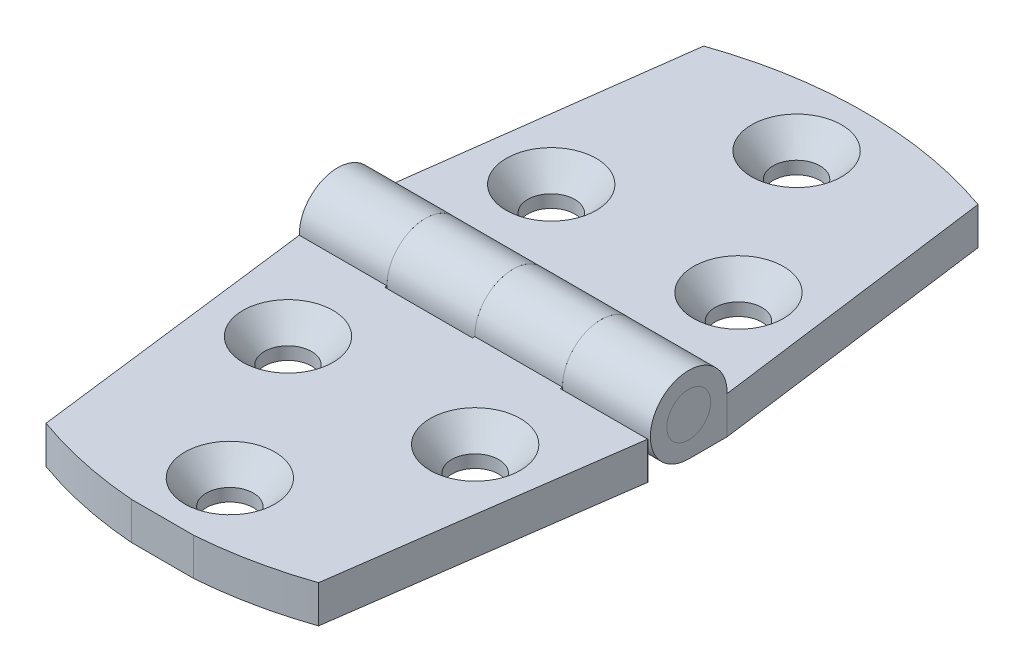
from build123d import *

# Parameters (mm, degrees)
SKETCH1_R                                    = 2.38125
LEFT_LEAF_DEPTH                              = 19.05
SKETCH2_W                                    = 9.525
SKETCH2_H                                    = 8.588375
CUT_EXTRUDE1_DEPTH                           = 5.1671875
CUT_EXTRUDE1_DEPTH_BACK                      = 5.1671875
SKETCH3_R                                    = 2.38125
RIGHT_LEAF_DEPTH                             = 19.05
SKETCH9_W                                    = 9.525
SKETCH9_H                                    = 8.842375
CUT_EXTRUDE2_DEPTH                           = 5.1671875
CUT_EXTRUDE2_DEPTH_BACK                      = 5.1671875
SKETCH10_R                                   = 2.38125
EXTRUDE1_DEPTH                               = 19.05
CUT_EXTRUDE3_DEPTH                           = 5.064
CSK_FOR_10_FLAT_HEAD_MACHINE_SCREW1_AT_COUNT = 2
CSK_FOR_10_FLAT_HEAD_MACHINE_SCREW1_AT_PITCH = 19.351919642
CSK_FOR_10_FLAT_HEAD_MACHINE_SCREW1_2_COUNT  = 2
CSK_FOR_10_FLAT_HEAD_MACHINE_SCREW1_2_PITCH  = 19.351919642
CSK_FOR_10_FLAT_HEAD_MACHINE_SCREW1_3_COUNT  = 2
CSK_FOR_10_FLAT_HEAD_MACHINE_SCREW1_3_PITCH  = 46.176896585
CSK_FOR_10_FLAT_HEAD_MACHINE_SCREW1_4_COUNT  = 2
CSK_FOR_10_FLAT_HEAD_MACHINE_SCREW1_4_PITCH  = 46.176896585
CSK_FOR_10_FLAT_HEAD_MACHINE_SCREW1_5_COUNT  = 2
CSK_FOR_10_FLAT_HEAD_MACHINE_SCREW1_5_PITCH  = 61.515625


with BuildPart() as part:
    # Sketch1 → Left Leaf (new body, symmetric)
    with BuildSketch(Plane(origin=(0, 0, 0), x_dir=(0, 0, -1), z_dir=(1, 0, 0))):
        with BuildLine():
            Line((-38.1, -0.1031875), (-4.165909745, -0.1031875))
            ThreePointArc((-4.165909745, -0.1031875), (2.909935566, 2.982905741), (0, -4.1671875))
            Line((0, -4.1671875), (-38.1, -4.1671875))
            Line((-38.1, -4.1671875), (-38.1, -0.1031875))
        make_face()
        Circle(SKETCH1_R, mode=Mode.SUBTRACT)
    extrude(amount=LEFT_LEAF_DEPTH, both=True)

    # Sketch2 → Cut-Extrude1 (cut, two sides)
    with BuildSketch(Plane(origin=(0, 0, 0), x_dir=(1, 0, 0), z_dir=(0, 1, 0))) as cut_extrude1_sk:
        with Locations((-4.7625, -0.127)):
            Rectangle(SKETCH2_W, SKETCH2_H)
        with Locations((14.2875, -0.127)):
            Rectangle(SKETCH2_W, SKETCH2_H)
    extrude(amount=CUT_EXTRUDE1_DEPTH, mode=Mode.SUBTRACT)
    extrude(cut_extrude1_sk.sketch, amount=-CUT_EXTRUDE1_DEPTH_BACK, mode=Mode.SUBTRACT)


with BuildPart() as body_2:
    # Sketch3 → Right Leaf (new body, symmetric)
    with BuildSketch(Plane(origin=(0, 0, 0), x_dir=(0, 0, -1), z_dir=(1, 0, 0))):
        with BuildLine():
            Line((38.1, -0.1031875), (38.1, -4.1671875))
            Line((38.1, -4.1671875), (0, -4.1671875))
            ThreePointArc((0, -4.1671875), (-2.909935566, 2.982905741), (4.165909745, -0.1031875))
            Line((4.165909745, -0.1031875), (38.1, -0.1031875))
        make_face()
        Circle(SKETCH3_R, mode=Mode.SUBTRACT)
    extrude(amount=RIGHT_LEAF_DEPTH, both=True)

    # Sketch9 → Cut-Extrude2 (cut, two sides)
    with BuildSketch(Plane(origin=(0, 0, 0), x_dir=(1, 0, 0), z_dir=(0, 1, 0))) as cut_extrude2_sk:
        with Locations((-14.2875, 0)):
            Rectangle(SKETCH9_W, SKETCH9_H)
        with Locations((4.7625, 0)):
            Rectangle(SKETCH9_W, SKETCH9_H)
    extrude(amount=CUT_EXTRUDE2_DEPTH, mode=Mode.SUBTRACT)
    extrude(cut_extrude2_sk.sketch, amount=-CUT_EXTRUDE2_DEPTH_BACK, mode=Mode.SUBTRACT)


with BuildPart() as body_3:
    # Sketch10 → Extrude1 (new body, symmetric)
    with BuildSketch(Plane(origin=(0, 0, 0), x_dir=(0, 0, -1), z_dir=(1, 0, 0))):
        Circle(SKETCH10_R)
    extrude(amount=EXTRUDE1_DEPTH, both=True)


with BuildPart() as cut_extrude3_tool:
    # Sketch13 → Cut-Extrude3 (new body, through all)
    with BuildSketch(Plane(origin=(0, -0.1031875, 0), x_dir=(-1, 0, 0), z_dir=(0, 1, 0))):
        with BuildLine():
            Line((19.022219059, -4.167094897), (14.889264695, -35.56))
            ThreePointArc((14.889264695, -35.56), (0, -38.1), (-14.889264695, -35.56))
            Line((-14.889264695, -35.56), (-19.05, -4.170764834))
            Line((-19.05, -4.170764834), (-24.251524546, -4.170764834))
            Line((-24.251524546, -4.170764834), (-24.251524546, -58.581674997))
            Line((-24.251524546, -58.581674997), (25.352500978, -58.581674997))
            Line((25.352500978, -58.581674997), (25.352500978, -4.167094897))
            Line((25.352500978, -4.167094897), (19.022219059, -4.167094897))
        make_face()
        with BuildLine():
            Line((-23.86002214, 58.869046819), (-24.22275751, 4.459345774))
            Line((-24.22275751, 4.459345774), (-19.021348553, 4.424669329))
            Line((-19.021348553, 4.424669329), (-14.651446465, 35.785469037))
            ThreePointArc((-14.651446465, 35.785469037), (0.254420506, 38.226151932), (15.126421188, 35.586947714))
            Line((15.126421188, 35.586947714), (19.05, 4.1671875))
            Line((19.05, 4.1671875), (25.380141248, 4.124986089))
            Line((25.380141248, 4.124986089), (25.742901085, 58.53835699))
            Line((25.742901085, 58.53835699), (-23.86002214, 58.869046819))
        make_face()
    extrude(amount=-CUT_EXTRUDE3_DEPTH)


with BuildPart() as part_1:
    add(part.part)

    # Cut-Extrude3: cut by cut_extrude3_tool
    add(cut_extrude3_tool.part, mode=Mode.SUBTRACT)


with BuildPart() as body_2_1:
    add(body_2.part)

    # Cut-Extrude3: cut by cut_extrude3_tool
    add(cut_extrude3_tool.part, mode=Mode.SUBTRACT)

    # Sketch12 → CSK for #10 Flat Head Machine Screw1 (revolve, cut)
    with BuildSketch(Plane(origin=(0, -0.1031875, -30.7578125), x_dir=(0, 0, 1), z_dir=(1, 0, 0))):
        Polygon((0, 0), (0, 4.064), (2.5527, 4.064), (2.5527, 2.688180894), (4.8895, 0), align=None)
    csk_for_10_flat_head_machine_screw1 = revolve(axis=Axis((0, 6.2468125, -30.7578125), (0, -1, 0)), mode=Mode.SUBTRACT)

    # CSK for #10 Flat Head Machine Screw1 at: CSK for #10 Flat Head Machine Screw1 ×2
    with Locations(*[Vector(-0.525012515, 0, 0.851094507) * (i * CSK_FOR_10_FLAT_HEAD_MACHINE_SCREW1_AT_PITCH) for i in range(1, CSK_FOR_10_FLAT_HEAD_MACHINE_SCREW1_AT_COUNT)]):
        add(csk_for_10_flat_head_machine_screw1, mode=Mode.SUBTRACT)

    # CSK for _10 Flat Head Machine Screw1 2: CSK for #10 Flat Head Machine Screw1 ×2
    with Locations(*[Vector(0.525012515, 0, 0.851094507) * (i * CSK_FOR_10_FLAT_HEAD_MACHINE_SCREW1_2_PITCH) for i in range(1, CSK_FOR_10_FLAT_HEAD_MACHINE_SCREW1_2_COUNT)]):
        add(csk_for_10_flat_head_machine_screw1, mode=Mode.SUBTRACT)


with BuildPart() as part_2:
    add(part_1.part)

    # CSK for _10 Flat Head Machine Screw1 3: CSK for #10 Flat Head Machine Screw1 ×2
    with Locations(*[Vector(-0.220023448, 0, 0.975494583) * (i * CSK_FOR_10_FLAT_HEAD_MACHINE_SCREW1_3_PITCH) for i in range(1, CSK_FOR_10_FLAT_HEAD_MACHINE_SCREW1_3_COUNT)]):
        add(csk_for_10_flat_head_machine_screw1, mode=Mode.SUBTRACT)

    # CSK for _10 Flat Head Machine Screw1 4: CSK for #10 Flat Head Machine Screw1 ×2
    with Locations(*[Vector(0.220023448, 0, 0.975494583) * (i * CSK_FOR_10_FLAT_HEAD_MACHINE_SCREW1_4_PITCH) for i in range(1, CSK_FOR_10_FLAT_HEAD_MACHINE_SCREW1_4_COUNT)]):
        add(csk_for_10_flat_head_machine_screw1, mode=Mode.SUBTRACT)

    # CSK for _10 Flat Head Machine Screw1 5: CSK for #10 Flat Head Machine Screw1 ×2
    with Locations(*[(0, 0, i * CSK_FOR_10_FLAT_HEAD_MACHINE_SCREW1_5_PITCH) for i in range(1, CSK_FOR_10_FLAT_HEAD_MACHINE_SCREW1_5_COUNT)]):
        add(csk_for_10_flat_head_machine_screw1, mode=Mode.SUBTRACT)


solid = Compound([body_3.part, body_2_1.part, part_2.part])
